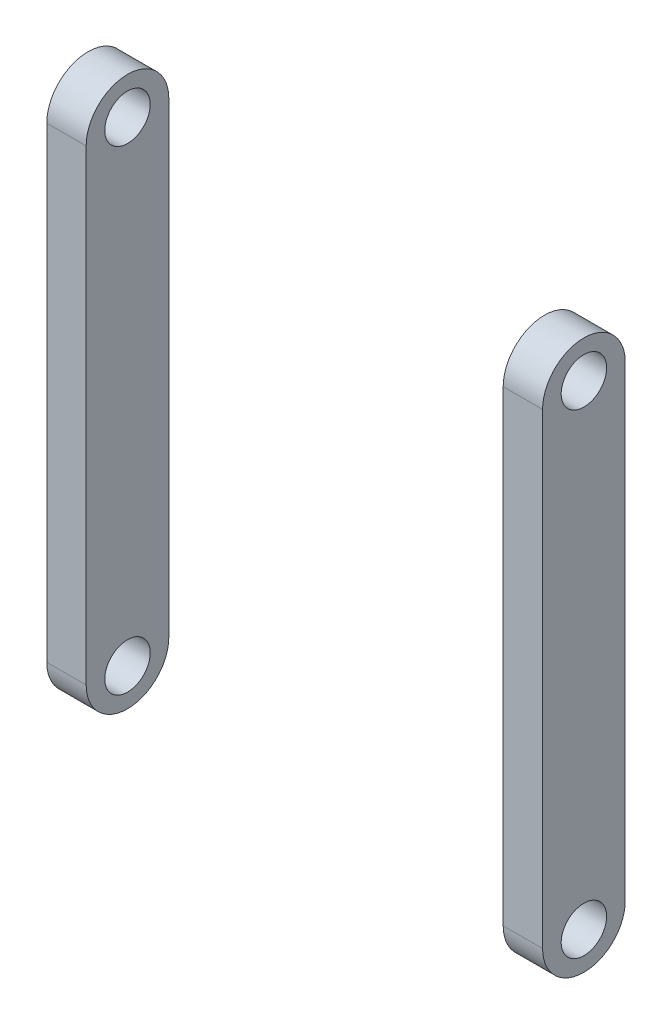
from build123d import *

# Parameters (mm, degrees)
SKETCH_1_W          = 1.906620372
SKETCH_1_H          = 27
EXTRUDE_1_DEPTH     = 4
EXTRUDE_1_2_DEPTH   = 4
SKETCH_2_R          = 1.1
CUT_EXTRUDE_6_DEPTH = 25


with BuildPart() as part:
    # 草图1 → 凸台-拉伸1 (new body)
    with BuildSketch(Plane.XY):
        with Locations((-13.453310186, -16.5)):
            Rectangle(SKETCH_1_W, SKETCH_1_H)
    extrude(amount=-EXTRUDE_1_DEPTH)


with BuildPart() as body_2:
    # 草图1 → Extrude 1 2 (new body)
    with BuildSketch(Plane.XY):
        with Locations((-35.546689814, -16.5)):
            Rectangle(SKETCH_1_W, SKETCH_1_H)
    extrude(amount=-EXTRUDE_1_2_DEPTH)


with BuildPart() as cut_extrude_6_tool:
    # 草图2 → 切除-拉伸6 (new body, through all)
    with BuildSketch(Plane(origin=(-12.5, 0, 0), x_dir=(0, 0, -1), z_dir=(1, 0, 0))):
        with BuildLine():
            Line((4, -3), (0, -3))
            Line((0, -3), (0, -5.2))
            ThreePointArc((0, -5.2), (2, -3.2), (4, -5.2))
            Line((4, -5.2), (4, -3))
        make_face()
        with BuildLine():
            ThreePointArc((4, -27.8), (1.999999998, -29.8), (0, -27.799999995))
            Line((0, -27.799999995), (0, -30))
            Line((0, -30), (4, -30))
            Line((4, -30), (4, -27.8))
        make_face()
        with Locations((2, -28)):
            Circle(SKETCH_2_R)
        with Locations((2, -5)):
            Circle(SKETCH_2_R)
    extrude(amount=-CUT_EXTRUDE_6_DEPTH)


with BuildPart() as part_1:
    add(part.part)

    # 切除-拉伸6: cut by cut_extrude_6_tool
    add(cut_extrude_6_tool.part, mode=Mode.SUBTRACT)


with BuildPart() as body_2_1:
    add(body_2.part)

    # 切除-拉伸6: cut by cut_extrude_6_tool
    add(cut_extrude_6_tool.part, mode=Mode.SUBTRACT)


solid = Compound([part_1.part, body_2_1.part])
